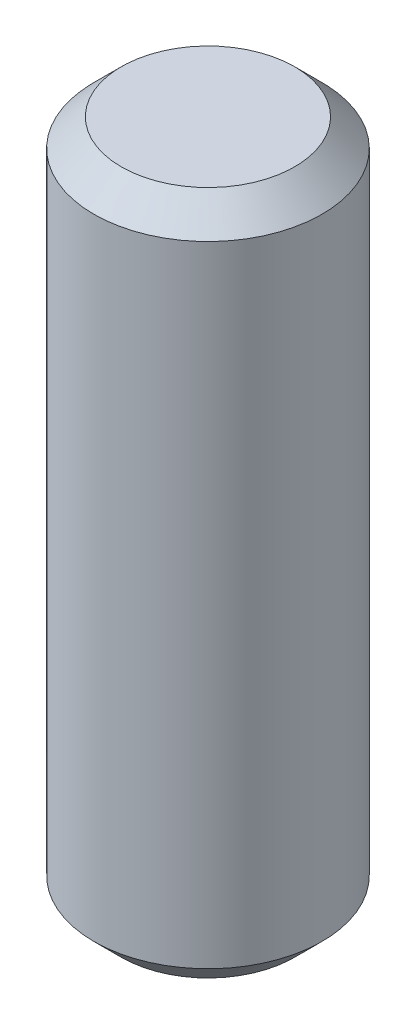
from build123d import *

# Parameters (mm, degrees)
SKETCH1_R           = 6.35
BOSS_EXTRUDE1_DEPTH = 19.05
CHAMFER1_SIZE       = 1.524


with BuildPart() as part:
    # Sketch1 → Boss-Extrude1 (new body, symmetric)
    with BuildSketch(Plane(origin=(0, 0, 0), x_dir=(1, 0, 0), z_dir=(0, 1, 0))):
        Circle(SKETCH1_R)
    extrude(amount=BOSS_EXTRUDE1_DEPTH, both=True)

    # Chamfer1
    chamfer1_edges = [part.edges().sort_by_distance(p)[0] for p in [
        (-6.35, -19.05, 0),
        (-6.35, 19.05, 0),
    ]]
    chamfer(chamfer1_edges, length=CHAMFER1_SIZE)


solid = part.part
